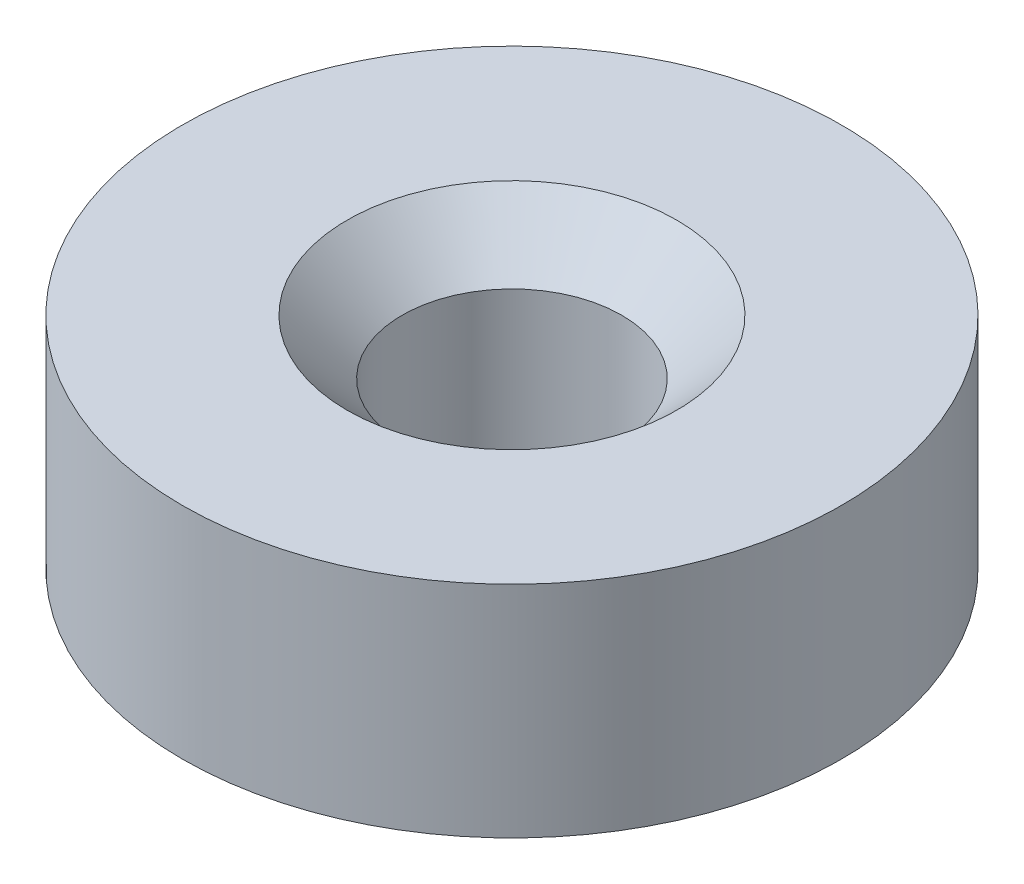
from build123d import *

# Parameters (mm, degrees)
SKETCH1_R           = 6
SKETCH1_R_2         = 2
BOSS_EXTRUDE1_DEPTH = 4
CHAMFER1_SIZE       = 1


with BuildPart() as part:
    # Sketch1 → Boss-Extrude1 (new body)
    with BuildSketch(Plane(origin=(0, 0, 0), x_dir=(1, 0, 0), z_dir=(0, 1, 0))):
        Circle(SKETCH1_R)
        Circle(SKETCH1_R_2, mode=Mode.SUBTRACT)
    extrude(amount=BOSS_EXTRUDE1_DEPTH)

    # Chamfer1
    chamfer1_edges = [part.edges().sort_by_distance(p)[0] for p in [
        (-2, 4, 0),
    ]]
    chamfer(chamfer1_edges, length=CHAMFER1_SIZE)


solid = part.part
